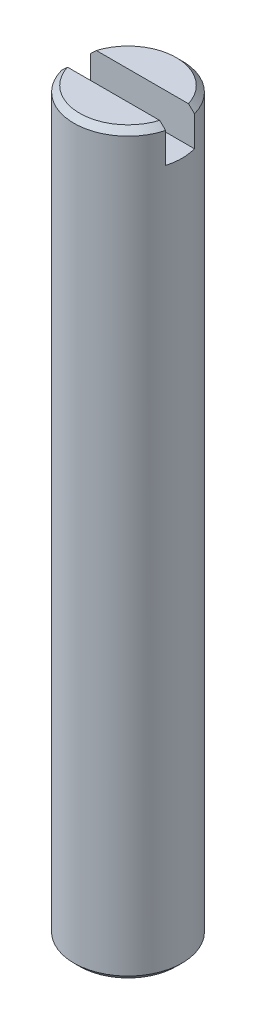
from build123d import *

# Parameters (mm, degrees)
SKETCH1_R           = 1.875
BOSS_EXTRUDE1_DEPTH = 25.63
CHAMFER1_SIZE       = 0.2
CHAMFER2_SIZE       = 0.2
SKETCH2_W           = 3.856306074
SKETCH2_H           = 1
CUT_EXTRUDE1_DEPTH  = 1.25


with BuildPart() as part:
    # Sketch1 → Boss-Extrude1 (new body)
    with BuildSketch(Plane(origin=(0, 0, 0), x_dir=(1, 0, 0), z_dir=(0, 1, 0))):
        Circle(SKETCH1_R)
    extrude(amount=BOSS_EXTRUDE1_DEPTH)

    # Chamfer1
    chamfer1_edges = [part.edges().sort_by_distance(p)[0] for p in [
        (-1.875, 25.63, 0),
    ]]
    chamfer(chamfer1_edges, length=CHAMFER1_SIZE)

    # Chamfer2
    chamfer2_edges = [part.edges().sort_by_distance(p)[0] for p in [
        (-1.875, 0, 0),
    ]]
    chamfer(chamfer2_edges, length=CHAMFER2_SIZE)

    # Sketch2 → Cut-Extrude1 (cut)
    with BuildSketch(Plane(origin=(0, 25.63, 0), x_dir=(1, 0, 0), z_dir=(0, 1, 0))):
        Rectangle(SKETCH2_W, SKETCH2_H)
    extrude(amount=-CUT_EXTRUDE1_DEPTH, mode=Mode.SUBTRACT)


solid = part.part
